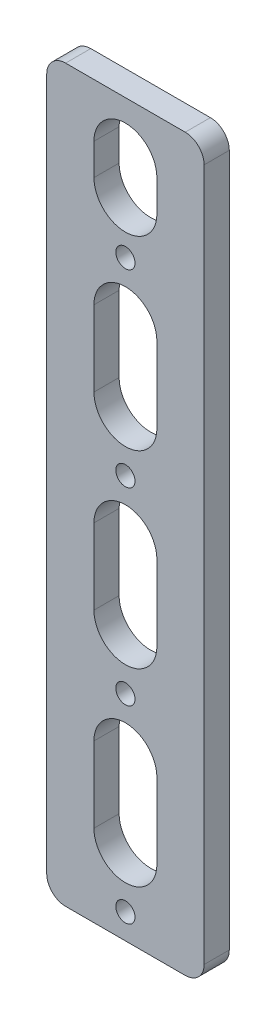
from build123d import *

# Parameters (mm, degrees)
SKETCH_1_W               = 25
SKETCH_1_H               = 116
EXTRUDE_1_DEPTH          = 4
SKETCH_2_R               = 1.525
CUT_EXTRUDE_1_DEPTH      = 1
CUT_EXTRUDE_1_DEPTH_BACK = 5
FILLET_1_R               = 3
CUT_EXTRUDE_2_DEPTH      = 1
CUT_EXTRUDE_2_DEPTH_BACK = 5


with BuildPart() as part:
    # 草图1 → 凸台-拉伸1 (new body)
    with BuildSketch(Plane.XY):
        Rectangle(SKETCH_1_W, SKETCH_1_H)
    extrude(amount=EXTRUDE_1_DEPTH)

    # 草图2 → 切除-拉伸1 (cut, two sides)
    with BuildSketch(Plane(origin=(0, 0, 0), x_dir=(-1, 0, 0), z_dir=(0, 0, -1))) as cut_extrude_1_sk:
        with Locations((0, -54.000000001)):
            Circle(SKETCH_2_R)
        with Locations((0, -24.000000001)):
            Circle(SKETCH_2_R)
        with Locations((0, 5.999999999)):
            Circle(SKETCH_2_R)
        with Locations((0, 35.999999999)):
            Circle(SKETCH_2_R)
    extrude(amount=CUT_EXTRUDE_1_DEPTH, mode=Mode.SUBTRACT)
    extrude(cut_extrude_1_sk.sketch, amount=-CUT_EXTRUDE_1_DEPTH_BACK, mode=Mode.SUBTRACT)

    # 圆角1
    fillet_1_edges = [part.edges().sort_by_distance(p)[0] for p in [
        (12.5, -58, 2),
        (-12.5, -58, 2),
        (-12.5, 58, 2),
        (12.5, 58, 2),
    ]]
    fillet(fillet_1_edges, radius=FILLET_1_R)

    # 草图4 → 切除-拉伸2 (cut, two sides)
    with BuildSketch(Plane.XY.offset(4)) as cut_extrude_2_sk:
        with BuildLine():
            Line((-5, 14.999999999), (-5, 26.999999999))
            ThreePointArc((-5, 26.999999999), (0, 31.999999999), (5, 26.999999999))
            Line((5, 26.999999999), (5, 14.999999999))
            ThreePointArc((5, 14.999999999), (0, 9.999999999), (-5, 14.999999999))
        make_face()
        with BuildLine():
            Line((-5, -45.000000001), (-5, -33.000000001))
            ThreePointArc((-5, -33.000000001), (0, -28.000000001), (5, -33.000000001))
            Line((5, -33.000000001), (5, -45.000000001))
            ThreePointArc((5, -45.000000001), (0, -50.000000001), (-5, -45.000000001))
        make_face()
        with BuildLine():
            Line((-5, -15.000000001), (-5, -3.000000001))
            ThreePointArc((-5, -3.000000001), (0, 1.999999999), (5, -3.000000001))
            Line((5, -3.000000001), (5, -15.000000001))
            ThreePointArc((5, -15.000000001), (0, -20.000000001), (-5, -15.000000001))
        make_face()
        with BuildLine():
            Line((-5, 44.499999999), (-5, 49.499999999))
            ThreePointArc((-5, 49.499999999), (0, 54.499999999), (5, 49.499999999))
            Line((5, 49.499999999), (5, 44.499999999))
            ThreePointArc((5, 44.499999999), (0, 39.499999999), (-5, 44.499999999))
        make_face()
    extrude(amount=CUT_EXTRUDE_2_DEPTH, mode=Mode.SUBTRACT)
    extrude(cut_extrude_2_sk.sketch, amount=-CUT_EXTRUDE_2_DEPTH_BACK, mode=Mode.SUBTRACT)


solid = part.part
